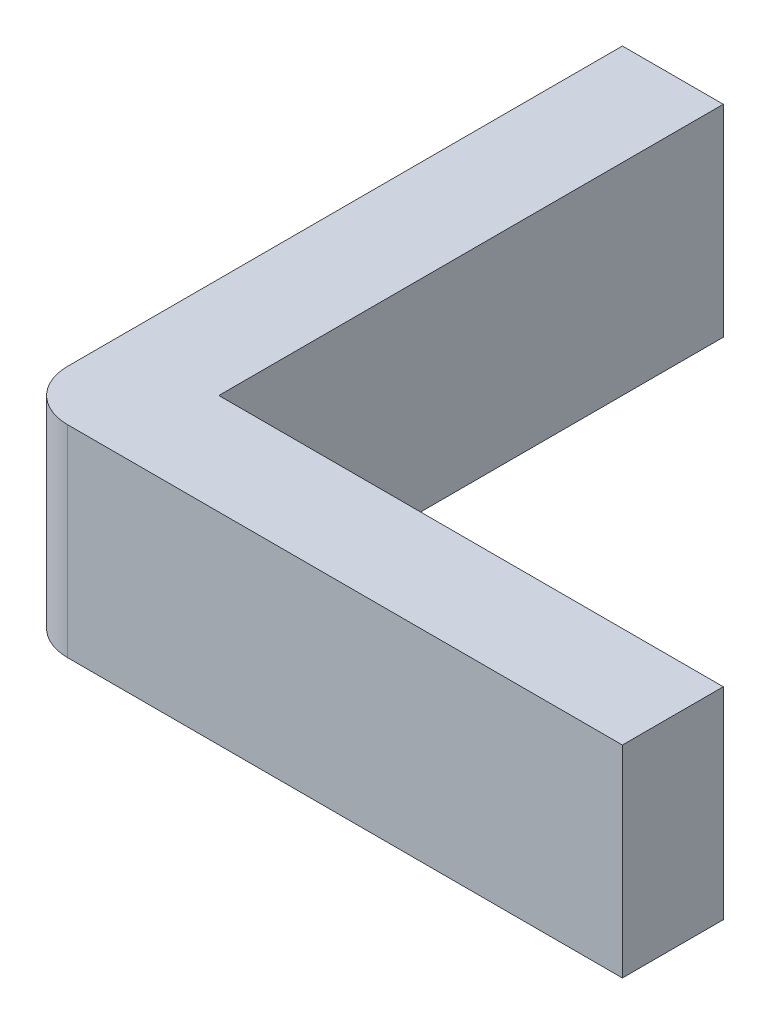
from build123d import *

# Parameters (mm, degrees)
BOSS_EXTRUDE1_DEPTH = 4
FILLET1_R           = 1


with BuildPart() as part:
    # Sketch1 → Boss-Extrude1 (new body)
    with BuildSketch(Plane(origin=(0, 0, 0), x_dir=(1, 0, 0), z_dir=(0, 1, 0))):
        Polygon((0, 0), (12, 0), (12, 2), (2, 2), (2, 12), (0, 12), align=None)
    extrude(amount=BOSS_EXTRUDE1_DEPTH)

    # Fillet1
    fillet1_edges = [part.edges().sort_by_distance(p)[0] for p in [
        (0, 2, 0),
    ]]
    fillet(fillet1_edges, radius=FILLET1_R)


solid = part.part
